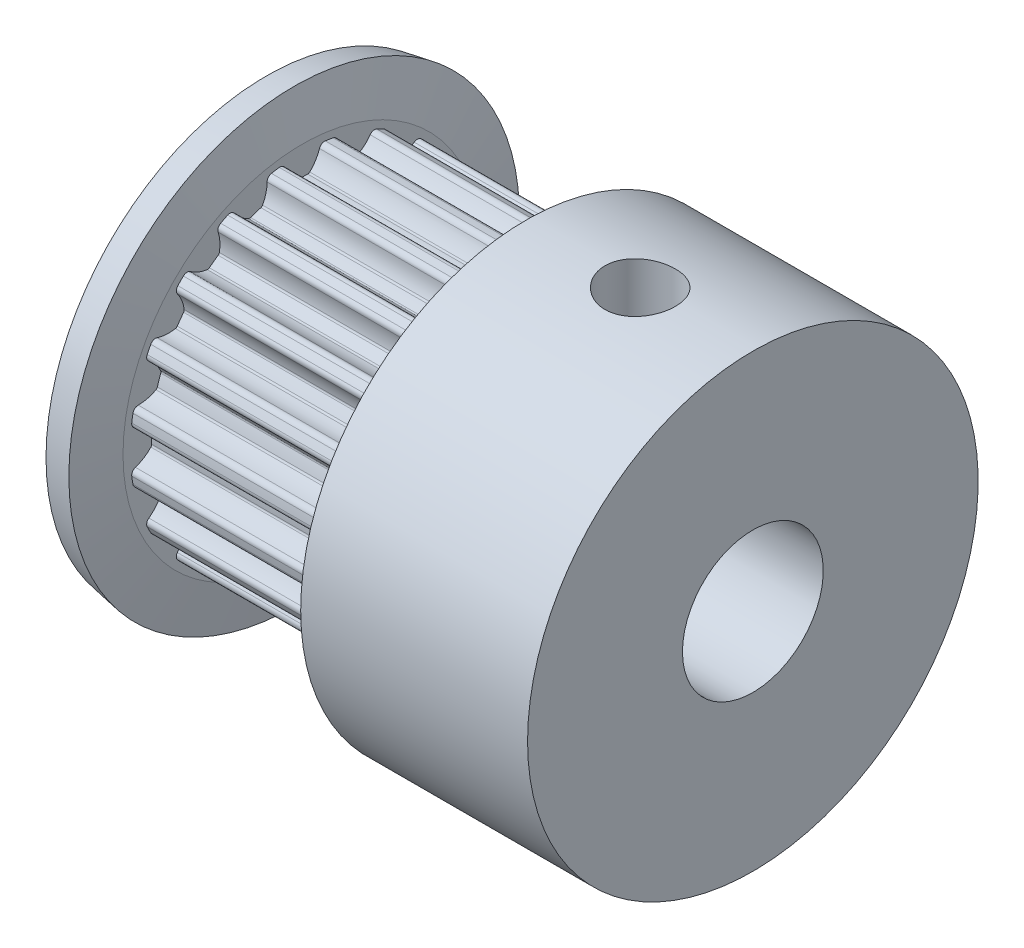
from build123d import *

# Parameters (mm, degrees)
CUT_EXTRUDE1_DEPTH         = 7
CUT_EXTRUDE2_DEPTH         = 7
CUT_EXTRUDE3_DEPTH         = 7
CUT_EXTRUDE4_DEPTH         = 7
CUT_EXTRUDE5_DEPTH         = 7
CUT_EXTRUDE6_DEPTH         = 7
CUT_EXTRUDE7_DEPTH         = 7
CUT_EXTRUDE8_DEPTH         = 7
CUT_EXTRUDE9_DEPTH         = 7
CUT_EXTRUDE10_DEPTH        = 7
CUT_EXTRUDE11_DEPTH        = 7
CUT_EXTRUDE12_DEPTH        = 7
CUT_EXTRUDE13_DEPTH        = 7
CUT_EXTRUDE14_DEPTH        = 7
CUT_EXTRUDE15_DEPTH        = 7
CUT_EXTRUDE16_DEPTH        = 7
CUT_EXTRUDE17_DEPTH        = 7
CUT_EXTRUDE18_DEPTH        = 7
CUT_EXTRUDE19_DEPTH        = 7
CUT_EXTRUDE20_DEPTH        = 7
M3X0_5_TAPPED_HOLE1_REACH  = 27.377
M3X0_5_TAPPED_HOLE1_BORE_R = 1.25


with BuildPart() as part:
    # Sketch1 → Revolve1 (revolve)
    with BuildSketch(Plane.XY, mode=Mode.PRIVATE) as revolve1_sk:
        Polygon((0, 5), (0, 2.5), (18, 2.5), (18, 8), (9.94396769, 8), (9, 6.365), (9, 6.11), (2, 6.11), (2, 6.365), (1.711705387, 8), (0.726897634, 7.826351822), (1, 6.277511336), (1, 5), align=None)
    revolve(revolve1_sk.sketch.rotate(Axis((19, 0, 0), (-1, 0, 0)), 270), axis=Axis((19, 0, 0), (-1, 0, 0)))

    # Sketch2 → Cut-Extrude1 (cut)
    with BuildSketch(Plane(origin=(2, 0, 0), x_dir=(0, 0, -1), z_dir=(1, 0, 0))):
        with BuildLine():
            Line((0.817312812, 6.05508875), (0.817312812, 8.146666667))
            Line((0.817312812, 8.146666667), (-0.817312812, 8.146666667))
            Line((-0.817312812, 8.146666667), (-0.817312812, 6.05508875))
            ThreePointArc((-0.817312812, 6.05508875), (-0.690592843, 6.027536553), (-0.611065194, 5.925104005))
            ThreePointArc((-0.611065194, 5.925104005), (-0.472761429, 5.628138755), (-0.265826496, 5.374181622))
            ThreePointArc((-0.265826496, 5.374181622), (-0.232263842, 5.352983727), (-0.193098212, 5.346514106))
            ThreePointArc((-0.193098212, 5.346514106), (-4e-09, 5.35), (0.193098203, 5.346514106))
            ThreePointArc((0.193098203, 5.346514106), (0.232263829, 5.352983722), (0.265826483, 5.374181609))
            ThreePointArc((0.265826483, 5.374181609), (0.472761423, 5.628138746), (0.611065194, 5.925104003))
            ThreePointArc((0.611065194, 5.925104003), (0.690592843, 6.027536553), (0.817312812, 6.05508875))
        make_face()
    extrude(amount=CUT_EXTRUDE1_DEPTH, mode=Mode.SUBTRACT)

    # Sketch3 → Cut-Extrude2 (cut)
    with BuildSketch(Plane(origin=(2, 0, 0), x_dir=(0, 0, -1), z_dir=(1, 0, 0))):
        with BuildLine():
            Line((-1.09381465, 6.011295161), (-1.740147772, 8.000503968))
            Line((-1.740147772, 8.000503968), (-3.294769123, 7.495376871))
            Line((-3.294769123, 7.495376871), (-2.648436002, 5.506168064))
            ThreePointArc((-2.648436002, 5.506168064), (-2.519404053, 5.519122992), (-2.412115366, 5.446279244))
            ThreePointArc((-2.412115366, 5.446279244), (-2.188813359, 5.206586721), (-1.913529474, 5.029005547))
            ThreePointArc((-1.913529474, 5.029005547), (-1.875058982, 5.019216581), (-1.835811032, 5.025166451))
            ThreePointArc((-1.835811032, 5.025166451), (-1.653240924, 5.088152361), (-1.468516415, 5.144507706))
            ThreePointArc((-1.468516415, 5.144507706), (-1.433266913, 5.162763521), (-1.40789744, 5.19329534))
            ThreePointArc((-1.40789744, 5.19329534), (-1.289567687, 5.498769343), (-1.249800296, 5.823938301))
            ThreePointArc((-1.249800296, 5.823938301), (-1.205818406, 5.94593284), (-1.09381465, 6.011295161))
        make_face()
    extrude(amount=CUT_EXTRUDE2_DEPTH, mode=Mode.SUBTRACT)

    # Sketch4 → Cut-Extrude3 (cut)
    with BuildSketch(Plane(origin=(2, 0, 0), x_dir=(0, 0, -1), z_dir=(1, 0, 0))):
        with BuildLine():
            Line((-2.897871914, 5.379074118), (-4.127270567, 7.071196198))
            Line((-4.127270567, 7.071196198), (-5.449710477, 6.110387363))
            Line((-5.449710477, 6.110387363), (-4.220311823, 4.418265284))
            ThreePointArc((-4.220311823, 4.418265284), (-4.10159844, 4.470459217), (-3.977050879, 4.434334724))
            ThreePointArc((-3.977050879, 4.434334724), (-3.690608988, 4.275377703), (-3.373922854, 4.191555369))
            ThreePointArc((-3.373922854, 4.191555369), (-3.334310286, 4.194133545), (-3.298821877, 4.211920491))
            ThreePointArc((-3.298821877, 4.211920491), (-3.144651103, 4.328240917), (-2.986382414, 4.438921048))
            ThreePointArc((-2.986382414, 4.438921048), (-2.958499503, 4.467176055), (-2.943806551, 4.504053139))
            ThreePointArc((-2.943806551, 4.504053139), (-2.925664927, 4.831142084), (-2.988326625, 5.152684941))
            ThreePointArc((-2.988326625, 5.152684941), (-2.984195748, 5.282299794), (-2.897871914, 5.379074118))
        make_face()
    extrude(amount=CUT_EXTRUDE3_DEPTH, mode=Mode.SUBTRACT)

    # Sketch5 → Cut-Extrude4 (cut)
    with BuildSketch(Plane(origin=(2, 0, 0), x_dir=(0, 0, -1), z_dir=(1, 0, 0))):
        with BuildLine():
            Line((-4.418265284, 4.220311823), (-6.110387363, 5.449710477))
            Line((-6.110387363, 5.449710477), (-7.071196198, 4.127270567))
            Line((-7.071196198, 4.127270567), (-5.379074118, 2.897871914))
            ThreePointArc((-5.379074118, 2.897871914), (-5.282299795, 2.984195747), (-5.152684942, 2.988326625))
            ThreePointArc((-5.152684942, 2.988326625), (-4.831142095, 2.925664928), (-4.504053158, 2.943806548))
            ThreePointArc((-4.504053158, 2.943806548), (-4.467176067, 2.958499496), (-4.438921053, 2.986382408))
            ThreePointArc((-4.438921053, 2.986382408), (-4.328240922, 3.144651096), (-4.211920496, 3.298821871))
            ThreePointArc((-4.211920496, 3.298821871), (-4.194133549, 3.334310272), (-4.191555367, 3.373922835))
            ThreePointArc((-4.191555367, 3.373922835), (-4.2753777, 3.690608978), (-4.434334723, 3.977050878))
            ThreePointArc((-4.434334723, 3.977050878), (-4.470459217, 4.101598439), (-4.418265284, 4.220311823))
        make_face()
    extrude(amount=CUT_EXTRUDE4_DEPTH, mode=Mode.SUBTRACT)

    # Sketch6 → Cut-Extrude5 (cut)
    with BuildSketch(Plane(origin=(2, 0, 0), x_dir=(0, 0, -1), z_dir=(1, 0, 0))):
        with BuildLine():
            Line((-5.506168064, 2.648436002), (-7.495376871, 3.294769123))
            Line((-7.495376871, 3.294769123), (-8.000503968, 1.740147772))
            Line((-8.000503968, 1.740147772), (-6.011295161, 1.09381465))
            ThreePointArc((-6.011295161, 1.09381465), (-5.945932841, 1.205818406), (-5.823938303, 1.249800296))
            ThreePointArc((-5.823938303, 1.249800296), (-5.498769353, 1.289567684), (-5.193295357, 1.407897431))
            ThreePointArc((-5.193295357, 1.407897431), (-5.16276353, 1.433266902), (-5.144507709, 1.468516407))
            ThreePointArc((-5.144507709, 1.468516407), (-5.088152363, 1.653240916), (-5.025166453, 1.835811024))
            ThreePointArc((-5.025166453, 1.835811024), (-5.01921658, 1.875058969), (-5.029005538, 1.913529457))
            ThreePointArc((-5.029005538, 1.913529457), (-5.206586715, 2.188813351), (-5.446279242, 2.412115365))
            ThreePointArc((-5.446279242, 2.412115365), (-5.519122991, 2.519404052), (-5.506168064, 2.648436002))
        make_face()
    extrude(amount=CUT_EXTRUDE5_DEPTH, mode=Mode.SUBTRACT)

    # Sketch7 → Cut-Extrude6 (cut)
    with BuildSketch(Plane(origin=(2, 0, 0), x_dir=(0, 0, -1), z_dir=(1, 0, 0))):
        with BuildLine():
            Line((-6.05508875, 0.817312812), (-8.146666667, 0.817312812))
            Line((-8.146666667, 0.817312812), (-8.146666667, -0.817312812))
            Line((-8.146666667, -0.817312812), (-6.05508875, -0.817312812))
            ThreePointArc((-6.05508875, -0.817312812), (-6.027536553, -0.690592843), (-5.925104005, -0.611065194))
            ThreePointArc((-5.925104005, -0.611065194), (-5.628138755, -0.472761429), (-5.374181622, -0.265826496))
            ThreePointArc((-5.374181622, -0.265826496), (-5.352983727, -0.232263842), (-5.346514106, -0.193098212))
            ThreePointArc((-5.346514106, -0.193098212), (-5.35, -4e-09), (-5.346514106, 0.193098203))
            ThreePointArc((-5.346514106, 0.193098203), (-5.352983722, 0.232263829), (-5.374181609, 0.265826483))
            ThreePointArc((-5.374181609, 0.265826483), (-5.628138746, 0.472761423), (-5.925104003, 0.611065194))
            ThreePointArc((-5.925104003, 0.611065194), (-6.027536553, 0.690592843), (-6.05508875, 0.817312812))
        make_face()
    extrude(amount=CUT_EXTRUDE6_DEPTH, mode=Mode.SUBTRACT)

    # Sketch8 → Cut-Extrude7 (cut)
    with BuildSketch(Plane(origin=(2, 0, 0), x_dir=(0, 0, -1), z_dir=(1, 0, 0))):
        with BuildLine():
            Line((-6.011295161, -1.09381465), (-8.000503968, -1.740147772))
            Line((-8.000503968, -1.740147772), (-7.495376871, -3.294769123))
            Line((-7.495376871, -3.294769123), (-5.506168064, -2.648436002))
            ThreePointArc((-5.506168064, -2.648436002), (-5.519122992, -2.519404053), (-5.446279244, -2.412115366))
            ThreePointArc((-5.446279244, -2.412115366), (-5.206586721, -2.188813359), (-5.029005547, -1.913529474))
            ThreePointArc((-5.029005547, -1.913529474), (-5.019216581, -1.875058982), (-5.025166451, -1.835811032))
            ThreePointArc((-5.025166451, -1.835811032), (-5.088152361, -1.653240924), (-5.144507706, -1.468516415))
            ThreePointArc((-5.144507706, -1.468516415), (-5.162763521, -1.433266913), (-5.19329534, -1.40789744))
            ThreePointArc((-5.19329534, -1.40789744), (-5.498769343, -1.289567687), (-5.823938301, -1.249800296))
            ThreePointArc((-5.823938301, -1.249800296), (-5.94593284, -1.205818406), (-6.011295161, -1.09381465))
        make_face()
    extrude(amount=CUT_EXTRUDE7_DEPTH, mode=Mode.SUBTRACT)

    # Sketch9 → Cut-Extrude8 (cut)
    with BuildSketch(Plane(origin=(2, 0, 0), x_dir=(0, 0, -1), z_dir=(1, 0, 0))):
        with BuildLine():
            Line((-5.379074118, -2.897871914), (-7.071196198, -4.127270567))
            Line((-7.071196198, -4.127270567), (-6.110387363, -5.449710477))
            Line((-6.110387363, -5.449710477), (-4.418265284, -4.220311823))
            ThreePointArc((-4.418265284, -4.220311823), (-4.470459217, -4.10159844), (-4.434334724, -3.977050879))
            ThreePointArc((-4.434334724, -3.977050879), (-4.275377703, -3.690608988), (-4.191555369, -3.373922854))
            ThreePointArc((-4.191555369, -3.373922854), (-4.194133545, -3.334310286), (-4.211920491, -3.298821877))
            ThreePointArc((-4.211920491, -3.298821877), (-4.328240917, -3.144651103), (-4.438921048, -2.986382414))
            ThreePointArc((-4.438921048, -2.986382414), (-4.467176055, -2.958499503), (-4.504053139, -2.943806551))
            ThreePointArc((-4.504053139, -2.943806551), (-4.831142084, -2.925664927), (-5.152684941, -2.988326625))
            ThreePointArc((-5.152684941, -2.988326625), (-5.282299794, -2.984195748), (-5.379074118, -2.897871914))
        make_face()
    extrude(amount=CUT_EXTRUDE8_DEPTH, mode=Mode.SUBTRACT)

    # Sketch10 → Cut-Extrude9 (cut)
    with BuildSketch(Plane(origin=(2, 0, 0), x_dir=(0, 0, -1), z_dir=(1, 0, 0))):
        with BuildLine():
            Line((-4.220311823, -4.418265284), (-5.449710477, -6.110387363))
            Line((-5.449710477, -6.110387363), (-4.127270567, -7.071196198))
            Line((-4.127270567, -7.071196198), (-2.897871914, -5.379074118))
            ThreePointArc((-2.897871914, -5.379074118), (-2.984195747, -5.282299795), (-2.988326625, -5.152684942))
            ThreePointArc((-2.988326625, -5.152684942), (-2.925664928, -4.831142095), (-2.943806548, -4.504053158))
            ThreePointArc((-2.943806548, -4.504053158), (-2.958499496, -4.467176067), (-2.986382408, -4.438921053))
            ThreePointArc((-2.986382408, -4.438921053), (-3.144651096, -4.328240922), (-3.298821871, -4.211920496))
            ThreePointArc((-3.298821871, -4.211920496), (-3.334310272, -4.194133549), (-3.373922835, -4.191555367))
            ThreePointArc((-3.373922835, -4.191555367), (-3.690608978, -4.2753777), (-3.977050878, -4.434334723))
            ThreePointArc((-3.977050878, -4.434334723), (-4.101598439, -4.470459217), (-4.220311823, -4.418265284))
        make_face()
    extrude(amount=CUT_EXTRUDE9_DEPTH, mode=Mode.SUBTRACT)

    # Sketch11 → Cut-Extrude10 (cut)
    with BuildSketch(Plane(origin=(2, 0, 0), x_dir=(0, 0, -1), z_dir=(1, 0, 0))):
        with BuildLine():
            Line((-2.648436002, -5.506168064), (-3.294769123, -7.495376871))
            Line((-3.294769123, -7.495376871), (-1.740147772, -8.000503968))
            Line((-1.740147772, -8.000503968), (-1.09381465, -6.011295161))
            ThreePointArc((-1.09381465, -6.011295161), (-1.205818406, -5.945932841), (-1.249800296, -5.823938303))
            ThreePointArc((-1.249800296, -5.823938303), (-1.289567684, -5.498769353), (-1.407897431, -5.193295357))
            ThreePointArc((-1.407897431, -5.193295357), (-1.433266902, -5.16276353), (-1.468516407, -5.144507709))
            ThreePointArc((-1.468516407, -5.144507709), (-1.653240916, -5.088152363), (-1.835811024, -5.025166453))
            ThreePointArc((-1.835811024, -5.025166453), (-1.875058969, -5.01921658), (-1.913529457, -5.029005538))
            ThreePointArc((-1.913529457, -5.029005538), (-2.188813351, -5.206586715), (-2.412115365, -5.446279242))
            ThreePointArc((-2.412115365, -5.446279242), (-2.519404052, -5.519122991), (-2.648436002, -5.506168064))
        make_face()
    extrude(amount=CUT_EXTRUDE10_DEPTH, mode=Mode.SUBTRACT)

    # Sketch12 → Cut-Extrude11 (cut)
    with BuildSketch(Plane(origin=(2, 0, 0), x_dir=(0, 0, -1), z_dir=(1, 0, 0))):
        with BuildLine():
            Line((-0.817312812, -6.05508875), (-0.817312812, -8.146666667))
            Line((-0.817312812, -8.146666667), (0.817312812, -8.146666667))
            Line((0.817312812, -8.146666667), (0.817312812, -6.05508875))
            ThreePointArc((0.817312812, -6.05508875), (0.690592843, -6.027536553), (0.611065194, -5.925104005))
            ThreePointArc((0.611065194, -5.925104005), (0.472761429, -5.628138755), (0.265826496, -5.374181622))
            ThreePointArc((0.265826496, -5.374181622), (0.232263842, -5.352983727), (0.193098212, -5.346514106))
            ThreePointArc((0.193098212, -5.346514106), (4e-09, -5.35), (-0.193098203, -5.346514106))
            ThreePointArc((-0.193098203, -5.346514106), (-0.232263829, -5.352983722), (-0.265826483, -5.374181609))
            ThreePointArc((-0.265826483, -5.374181609), (-0.472761423, -5.628138746), (-0.611065194, -5.925104003))
            ThreePointArc((-0.611065194, -5.925104003), (-0.690592843, -6.027536553), (-0.817312812, -6.05508875))
        make_face()
    extrude(amount=CUT_EXTRUDE11_DEPTH, mode=Mode.SUBTRACT)

    # Sketch13 → Cut-Extrude12 (cut)
    with BuildSketch(Plane(origin=(2, 0, 0), x_dir=(0, 0, -1), z_dir=(1, 0, 0))):
        with BuildLine():
            Line((1.09381465, -6.011295161), (1.740147772, -8.000503968))
            Line((1.740147772, -8.000503968), (3.294769123, -7.495376871))
            Line((3.294769123, -7.495376871), (2.648436002, -5.506168064))
            ThreePointArc((2.648436002, -5.506168064), (2.519404053, -5.519122992), (2.412115366, -5.446279244))
            ThreePointArc((2.412115366, -5.446279244), (2.188813359, -5.206586721), (1.913529474, -5.029005547))
            ThreePointArc((1.913529474, -5.029005547), (1.875058982, -5.019216581), (1.835811032, -5.025166451))
            ThreePointArc((1.835811032, -5.025166451), (1.653240924, -5.088152361), (1.468516415, -5.144507706))
            ThreePointArc((1.468516415, -5.144507706), (1.433266913, -5.162763521), (1.40789744, -5.19329534))
            ThreePointArc((1.40789744, -5.19329534), (1.289567687, -5.498769343), (1.249800296, -5.823938301))
            ThreePointArc((1.249800296, -5.823938301), (1.205818406, -5.94593284), (1.09381465, -6.011295161))
        make_face()
    extrude(amount=CUT_EXTRUDE12_DEPTH, mode=Mode.SUBTRACT)

    # Sketch14 → Cut-Extrude13 (cut)
    with BuildSketch(Plane(origin=(2, 0, 0), x_dir=(0, 0, -1), z_dir=(1, 0, 0))):
        with BuildLine():
            Line((2.897871914, -5.379074118), (4.127270567, -7.071196198))
            Line((4.127270567, -7.071196198), (5.449710477, -6.110387363))
            Line((5.449710477, -6.110387363), (4.220311823, -4.418265284))
            ThreePointArc((4.220311823, -4.418265284), (4.10159844, -4.470459217), (3.977050879, -4.434334724))
            ThreePointArc((3.977050879, -4.434334724), (3.690608988, -4.275377703), (3.373922854, -4.191555369))
            ThreePointArc((3.373922854, -4.191555369), (3.334310286, -4.194133545), (3.298821877, -4.211920491))
            ThreePointArc((3.298821877, -4.211920491), (3.144651103, -4.328240917), (2.986382414, -4.438921048))
            ThreePointArc((2.986382414, -4.438921048), (2.958499503, -4.467176055), (2.943806551, -4.504053139))
            ThreePointArc((2.943806551, -4.504053139), (2.925664927, -4.831142084), (2.988326625, -5.152684941))
            ThreePointArc((2.988326625, -5.152684941), (2.984195748, -5.282299794), (2.897871914, -5.379074118))
        make_face()
    extrude(amount=CUT_EXTRUDE13_DEPTH, mode=Mode.SUBTRACT)

    # Sketch15 → Cut-Extrude14 (cut)
    with BuildSketch(Plane(origin=(2, 0, 0), x_dir=(0, 0, -1), z_dir=(1, 0, 0))):
        with BuildLine():
            Line((4.418265284, -4.220311823), (6.110387363, -5.449710477))
            Line((6.110387363, -5.449710477), (7.071196198, -4.127270567))
            Line((7.071196198, -4.127270567), (5.379074118, -2.897871914))
            ThreePointArc((5.379074118, -2.897871914), (5.282299795, -2.984195747), (5.152684942, -2.988326625))
            ThreePointArc((5.152684942, -2.988326625), (4.831142095, -2.925664928), (4.504053158, -2.943806548))
            ThreePointArc((4.504053158, -2.943806548), (4.467176067, -2.958499496), (4.438921053, -2.986382408))
            ThreePointArc((4.438921053, -2.986382408), (4.328240922, -3.144651096), (4.211920496, -3.298821871))
            ThreePointArc((4.211920496, -3.298821871), (4.194133549, -3.334310272), (4.191555367, -3.373922835))
            ThreePointArc((4.191555367, -3.373922835), (4.2753777, -3.690608978), (4.434334723, -3.977050878))
            ThreePointArc((4.434334723, -3.977050878), (4.470459217, -4.101598439), (4.418265284, -4.220311823))
        make_face()
    extrude(amount=CUT_EXTRUDE14_DEPTH, mode=Mode.SUBTRACT)

    # Sketch16 → Cut-Extrude15 (cut)
    with BuildSketch(Plane(origin=(2, 0, 0), x_dir=(0, 0, -1), z_dir=(1, 0, 0))):
        with BuildLine():
            Line((5.506168064, -2.648436002), (7.495376871, -3.294769123))
            Line((7.495376871, -3.294769123), (8.000503968, -1.740147772))
            Line((8.000503968, -1.740147772), (6.011295161, -1.09381465))
            ThreePointArc((6.011295161, -1.09381465), (5.945932841, -1.205818406), (5.823938303, -1.249800296))
            ThreePointArc((5.823938303, -1.249800296), (5.498769353, -1.289567684), (5.193295357, -1.407897431))
            ThreePointArc((5.193295357, -1.407897431), (5.16276353, -1.433266902), (5.144507709, -1.468516407))
            ThreePointArc((5.144507709, -1.468516407), (5.088152363, -1.653240916), (5.025166453, -1.835811024))
            ThreePointArc((5.025166453, -1.835811024), (5.01921658, -1.875058969), (5.029005538, -1.913529457))
            ThreePointArc((5.029005538, -1.913529457), (5.206586715, -2.188813351), (5.446279242, -2.412115365))
            ThreePointArc((5.446279242, -2.412115365), (5.519122991, -2.519404052), (5.506168064, -2.648436002))
        make_face()
    extrude(amount=CUT_EXTRUDE15_DEPTH, mode=Mode.SUBTRACT)

    # Sketch17 → Cut-Extrude16 (cut)
    with BuildSketch(Plane(origin=(2, 0, 0), x_dir=(0, 0, -1), z_dir=(1, 0, 0))):
        with BuildLine():
            Line((6.05508875, -0.817312812), (8.146666667, -0.817312812))
            Line((8.146666667, -0.817312812), (8.146666667, 0.817312812))
            Line((8.146666667, 0.817312812), (6.05508875, 0.817312812))
            ThreePointArc((6.05508875, 0.817312812), (6.027536553, 0.690592843), (5.925104005, 0.611065194))
            ThreePointArc((5.925104005, 0.611065194), (5.628138755, 0.472761429), (5.374181622, 0.265826496))
            ThreePointArc((5.374181622, 0.265826496), (5.352983727, 0.232263842), (5.346514106, 0.193098212))
            ThreePointArc((5.346514106, 0.193098212), (5.35, 4e-09), (5.346514106, -0.193098203))
            ThreePointArc((5.346514106, -0.193098203), (5.352983722, -0.232263829), (5.374181609, -0.265826483))
            ThreePointArc((5.374181609, -0.265826483), (5.628138746, -0.472761423), (5.925104003, -0.611065194))
            ThreePointArc((5.925104003, -0.611065194), (6.027536553, -0.690592843), (6.05508875, -0.817312812))
        make_face()
    extrude(amount=CUT_EXTRUDE16_DEPTH, mode=Mode.SUBTRACT)

    # Sketch18 → Cut-Extrude17 (cut)
    with BuildSketch(Plane(origin=(2, 0, 0), x_dir=(0, 0, -1), z_dir=(1, 0, 0))):
        with BuildLine():
            Line((6.011295161, 1.09381465), (8.000503968, 1.740147772))
            Line((8.000503968, 1.740147772), (7.495376871, 3.294769123))
            Line((7.495376871, 3.294769123), (5.506168064, 2.648436002))
            ThreePointArc((5.506168064, 2.648436002), (5.519122992, 2.519404053), (5.446279244, 2.412115366))
            ThreePointArc((5.446279244, 2.412115366), (5.206586721, 2.188813359), (5.029005547, 1.913529474))
            ThreePointArc((5.029005547, 1.913529474), (5.019216581, 1.875058982), (5.025166451, 1.835811032))
            ThreePointArc((5.025166451, 1.835811032), (5.088152361, 1.653240924), (5.144507706, 1.468516415))
            ThreePointArc((5.144507706, 1.468516415), (5.162763521, 1.433266913), (5.19329534, 1.40789744))
            ThreePointArc((5.19329534, 1.40789744), (5.498769343, 1.289567687), (5.823938301, 1.249800296))
            ThreePointArc((5.823938301, 1.249800296), (5.94593284, 1.205818406), (6.011295161, 1.09381465))
        make_face()
    extrude(amount=CUT_EXTRUDE17_DEPTH, mode=Mode.SUBTRACT)

    # Sketch19 → Cut-Extrude18 (cut)
    with BuildSketch(Plane(origin=(2, 0, 0), x_dir=(0, 0, -1), z_dir=(1, 0, 0))):
        with BuildLine():
            Line((5.379074118, 2.897871914), (7.071196198, 4.127270567))
            Line((7.071196198, 4.127270567), (6.110387363, 5.449710477))
            Line((6.110387363, 5.449710477), (4.418265284, 4.220311823))
            ThreePointArc((4.418265284, 4.220311823), (4.470459217, 4.10159844), (4.434334724, 3.977050879))
            ThreePointArc((4.434334724, 3.977050879), (4.275377703, 3.690608988), (4.191555369, 3.373922854))
            ThreePointArc((4.191555369, 3.373922854), (4.194133545, 3.334310286), (4.211920491, 3.298821877))
            ThreePointArc((4.211920491, 3.298821877), (4.328240917, 3.144651103), (4.438921048, 2.986382414))
            ThreePointArc((4.438921048, 2.986382414), (4.467176055, 2.958499503), (4.504053139, 2.943806551))
            ThreePointArc((4.504053139, 2.943806551), (4.831142084, 2.925664927), (5.152684941, 2.988326625))
            ThreePointArc((5.152684941, 2.988326625), (5.282299794, 2.984195748), (5.379074118, 2.897871914))
        make_face()
    extrude(amount=CUT_EXTRUDE18_DEPTH, mode=Mode.SUBTRACT)

    # Sketch20 → Cut-Extrude19 (cut)
    with BuildSketch(Plane(origin=(2, 0, 0), x_dir=(0, 0, -1), z_dir=(1, 0, 0))):
        with BuildLine():
            Line((4.220311823, 4.418265284), (5.449710477, 6.110387363))
            Line((5.449710477, 6.110387363), (4.127270567, 7.071196198))
            Line((4.127270567, 7.071196198), (2.897871914, 5.379074118))
            ThreePointArc((2.897871914, 5.379074118), (2.984195747, 5.282299795), (2.988326625, 5.152684942))
            ThreePointArc((2.988326625, 5.152684942), (2.925664928, 4.831142095), (2.943806548, 4.504053158))
            ThreePointArc((2.943806548, 4.504053158), (2.958499496, 4.467176067), (2.986382408, 4.438921053))
            ThreePointArc((2.986382408, 4.438921053), (3.144651096, 4.328240922), (3.298821871, 4.211920496))
            ThreePointArc((3.298821871, 4.211920496), (3.334310272, 4.194133549), (3.373922835, 4.191555367))
            ThreePointArc((3.373922835, 4.191555367), (3.690608978, 4.2753777), (3.977050878, 4.434334723))
            ThreePointArc((3.977050878, 4.434334723), (4.101598439, 4.470459217), (4.220311823, 4.418265284))
        make_face()
    extrude(amount=CUT_EXTRUDE19_DEPTH, mode=Mode.SUBTRACT)

    # Sketch21 → Cut-Extrude20 (cut)
    with BuildSketch(Plane(origin=(2, 0, 0), x_dir=(0, 0, -1), z_dir=(1, 0, 0))):
        with BuildLine():
            Line((2.648436002, 5.506168064), (3.294769123, 7.495376871))
            Line((3.294769123, 7.495376871), (1.740147772, 8.000503968))
            Line((1.740147772, 8.000503968), (1.09381465, 6.011295161))
            ThreePointArc((1.09381465, 6.011295161), (1.205818406, 5.945932841), (1.249800296, 5.823938303))
            ThreePointArc((1.249800296, 5.823938303), (1.289567684, 5.498769353), (1.407897431, 5.193295357))
            ThreePointArc((1.407897431, 5.193295357), (1.433266902, 5.16276353), (1.468516407, 5.144507709))
            ThreePointArc((1.468516407, 5.144507709), (1.653240916, 5.088152363), (1.835811024, 5.025166453))
            ThreePointArc((1.835811024, 5.025166453), (1.875058969, 5.01921658), (1.913529457, 5.029005538))
            ThreePointArc((1.913529457, 5.029005538), (2.188813351, 5.206586715), (2.412115365, 5.446279242))
            ThreePointArc((2.412115365, 5.446279242), (2.519404052, 5.519122991), (2.648436002, 5.506168064))
        make_face()
    extrude(amount=CUT_EXTRUDE20_DEPTH, mode=Mode.SUBTRACT)

    # M3x0.5 Tapped Hole1 bore → M3x0.5 Tapped Hole1 (cut, up to next)
    with BuildSketch(Plane(origin=(0, 8, 0), x_dir=(1, 0, 0), z_dir=(0, 1, 0)), mode=Mode.PRIVATE) as m3x0_5_tapped_hole1_sk1:
        with Locations((14, 0)):
            Circle(M3X0_5_TAPPED_HOLE1_BORE_R)
    m3x0_5_tapped_hole1_tool1 = extrude(m3x0_5_tapped_hole1_sk1.sketch, amount=-M3X0_5_TAPPED_HOLE1_REACH, mode=Mode.PRIVATE) & part.part
    add(m3x0_5_tapped_hole1_tool1.solids().sort_by_distance((14, 8, 0))[0], mode=Mode.SUBTRACT)


solid = part.part
